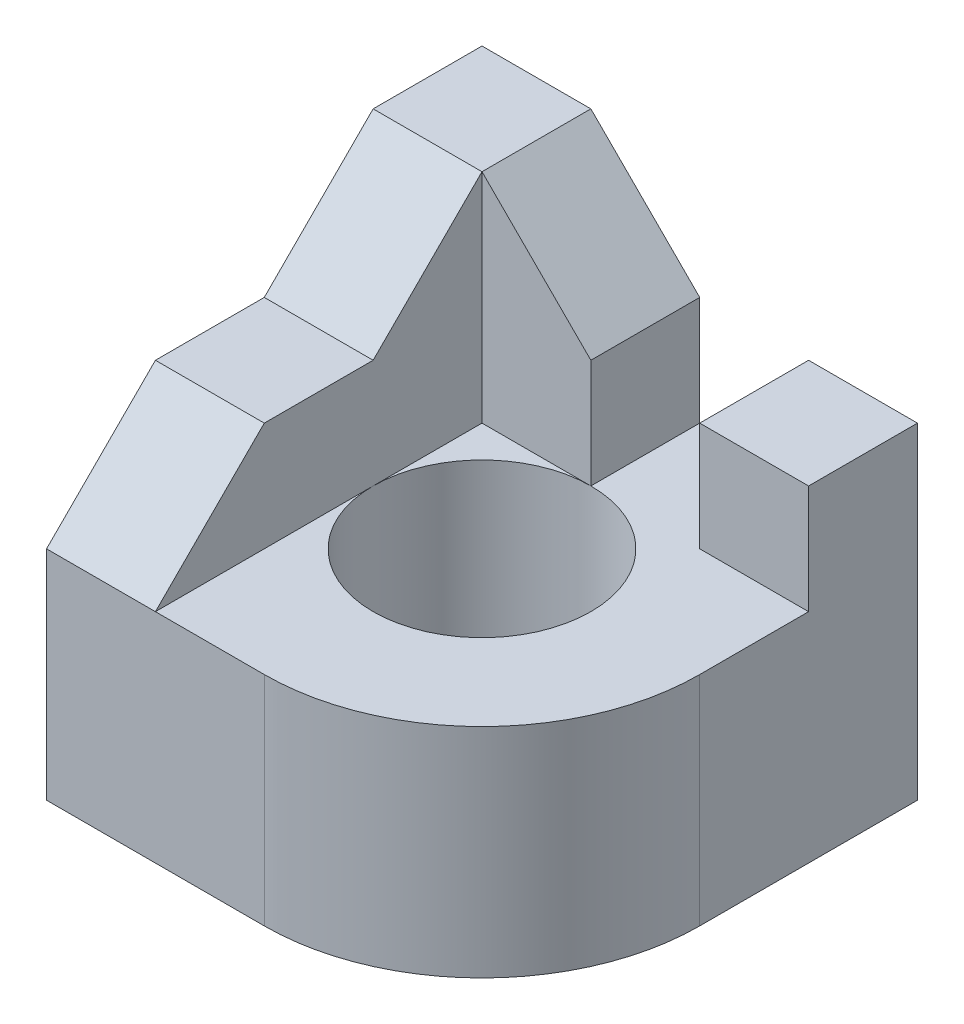
from build123d import *

# Parameters (mm, degrees)
SKETCH1_W               = 10
SKETCH1_H               = 10
BOSS_EXTRUDE1_DEPTH     = 20
SKETCH1_3_W             = 10
SKETCH1_3_H             = 10
BOSS_EXTRUDE2_DEPTH     = 30
SKETCH1_4_W             = 10
SKETCH1_4_H             = 10
BOSS_EXTRUDE3_DEPTH     = 40
CUT_EXTRUDE1_DEPTH      = 31
CUT_EXTRUDE1_DEPTH_BACK = 10
CUT_EXTRUDE2_DEPTH      = 31
CUT_EXTRUDE2_DEPTH_BACK = 10


with BuildPart() as part:
    # Sketch1 → Boss-Extrude1 (new body)
    with BuildSketch(Plane(origin=(0, 0, 0), x_dir=(1, 0, 0), z_dir=(0, 1, 0))):
        Polygon((10, 0), (0, 0), (0, -40), (10, -40), (10, -20), (10, -10), align=None)
        with BuildLine():
            Line((10, -20), (10, -40))
            Line((10, -40), (20, -40))
            ThreePointArc((20, -40), (34.142135624, -34.142135624), (40, -20))
            Line((40, -20), (40, -10))
            Line((40, -10), (30, -10))
            Line((30, -10), (30, 0))
            Line((30, 0), (20, 0))
            Line((20, 0), (20, -10))
            ThreePointArc((20, -10), (27.071067812, -12.928932188), (30, -20))
            ThreePointArc((30, -20), (20, -30), (10, -20))
        make_face()
        with Locations((15, -5)):
            Rectangle(SKETCH1_W, SKETCH1_H)
        with Locations((35, -5)):
            Rectangle(SKETCH1_W, SKETCH1_H)
        with BuildLine():
            Line((20, -10), (10, -10))
            Line((10, -10), (10, -20))
            ThreePointArc((10, -20), (12.928932188, -12.928932188), (20, -10))
        make_face()
    extrude(amount=BOSS_EXTRUDE1_DEPTH)

    # Sketch1_3 → Boss-Extrude2 (add)
    with BuildSketch(Plane(origin=(0, 0, 0), x_dir=(1, 0, 0), z_dir=(0, 1, 0))):
        with Locations((35, -5)):
            Rectangle(SKETCH1_3_W, SKETCH1_3_H)
    extrude(amount=BOSS_EXTRUDE2_DEPTH)

    # Sketch1_4 → Boss-Extrude3 (add)
    with BuildSketch(Plane(origin=(0, 0, 0), x_dir=(1, 0, 0), z_dir=(0, 1, 0))):
        with Locations((15, -5)):
            Rectangle(SKETCH1_4_W, SKETCH1_4_H)
        Polygon((10, 0), (0, 0), (0, -40), (10, -40), (10, -20), (10, -10), align=None)
    extrude(amount=BOSS_EXTRUDE3_DEPTH)

    # Sketch2 → Cut-Extrude1 (cut, two sides)
    with BuildSketch(Plane.XY.offset(10)) as cut_extrude1_sk:
        Polygon((20, 40), (10, 40), (20, 30), align=None)
    extrude(amount=CUT_EXTRUDE1_DEPTH, mode=Mode.SUBTRACT)
    extrude(cut_extrude1_sk.sketch, amount=-CUT_EXTRUDE1_DEPTH_BACK, mode=Mode.SUBTRACT)

    # Sketch3 → Cut-Extrude2 (cut, two sides)
    with BuildSketch(Plane(origin=(10, 0, 0), x_dir=(0, 0, -1), z_dir=(1, 0, 0))) as cut_extrude2_sk:
        Polygon((-117.781745931, -57.781745931), (-40, 20), (-30, 30), (-20, 30), (-10, 40), (67.781745931, 117.781745931), (-83.416065326, 277.591701412), (-268.979557187, 102.028209551), align=None)
    extrude(amount=CUT_EXTRUDE2_DEPTH, mode=Mode.SUBTRACT)
    extrude(cut_extrude2_sk.sketch, amount=-CUT_EXTRUDE2_DEPTH_BACK, mode=Mode.SUBTRACT)


solid = part.part
